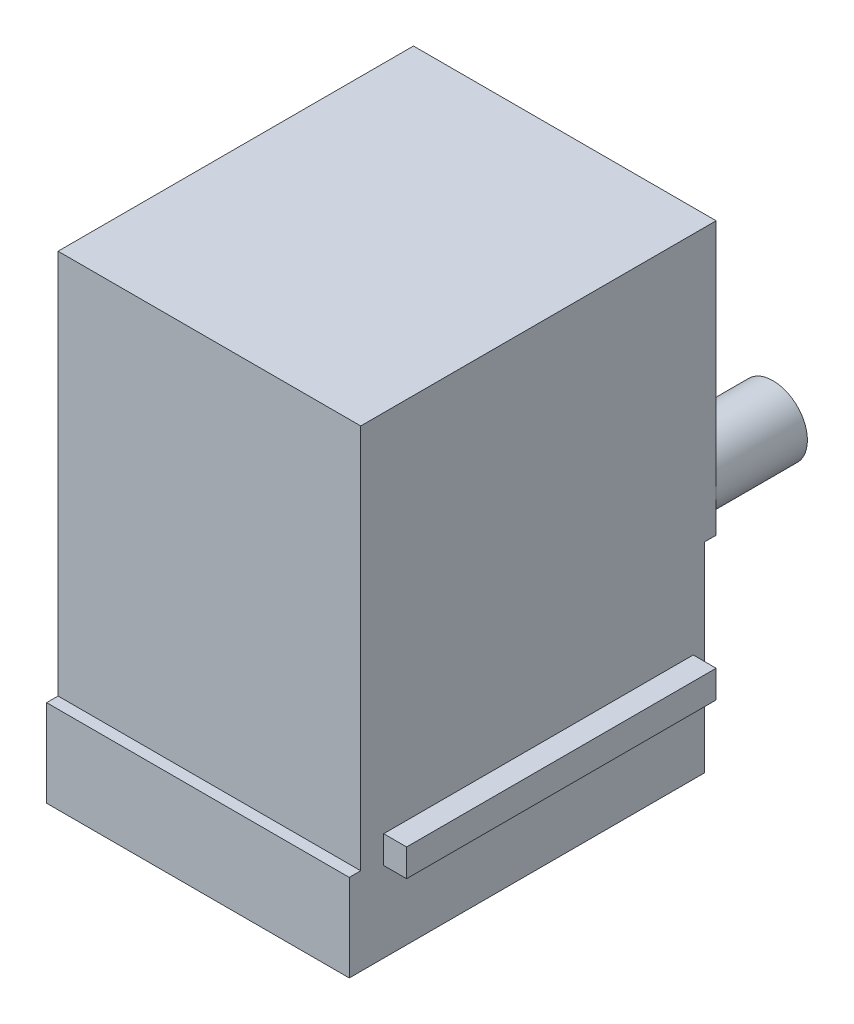
from build123d import *

# Parameters (mm, degrees)
SKETCH1_W           = 13.2
SKETCH1_H           = 20.6
BOSS_EXTRUDE1_DEPTH = 15.5
SKETCH2_R           = 1.5
BOSS_EXTRUDE2_DEPTH = 4
SKETCH3_W           = 13.2
SKETCH3_H           = 3.8
BOSS_EXTRUDE3_DEPTH = 0.5
CUT_EXTRUDE1_DEPTH  = 11
SKETCH5_W           = 4.1
SKETCH5_H           = 2.2
CUT_EXTRUDE2_DEPTH  = 5
SKETCH6_W           = 13.5
SKETCH6_H           = 1.2
BOSS_EXTRUDE5_DEPTH = 1
SKETCH7_W           = 13.5
SKETCH7_H           = 1.2
BOSS_EXTRUDE6_DEPTH = 1
SKETCH8_W           = 13.2
SKETCH8_H           = 8.722289783
CUT_EXTRUDE3_DEPTH  = 0.5


with BuildPart() as part:
    # Sketch1 → Boss-Extrude1 (new body)
    with BuildSketch(Plane.XY):
        Rectangle(SKETCH1_W, SKETCH1_H)
    extrude(amount=BOSS_EXTRUDE1_DEPTH)

    # Sketch2 → Boss-Extrude2 (add)
    with BuildSketch(Plane(origin=(0, 0, 0), x_dir=(-1, 0, 0), z_dir=(0, 0, -1))):
        with Locations((5.08, 0)):
            Circle(SKETCH2_R)
        with Locations((-5.08, 0)):
            Circle(SKETCH2_R)
    extrude(amount=BOSS_EXTRUDE2_DEPTH)

    # Sketch3 → Boss-Extrude3 (add)
    with BuildSketch(Plane.XY.offset(15.5)):
        with Locations((0, -8.4)):
            Rectangle(SKETCH3_W, SKETCH3_H)
    extrude(amount=BOSS_EXTRUDE3_DEPTH)

    # Sketch4 → Cut-Extrude1 (cut)
    with BuildSketch(Plane.XZ.offset(10.3)):
        Polygon((-3.6, 15), (3.6, 15), (3.6, 13), (4.6, 13), (4.6, 11), (5.6, 11), (5.6, 8.4), (4.6, 8.4), (4.6, 6.1), (3.6, 6.1), (3.6, 4), (-3.6, 4), (-3.6, 6.1), (-4.6, 6.1), (-4.6, 8.4), (-5.6, 8.4), (-5.6, 11), (-4.6, 11), (-4.6, 13), (-3.6, 13), align=None)
    extrude(amount=-CUT_EXTRUDE1_DEPTH, mode=Mode.SUBTRACT)

    # Sketch5 → Cut-Extrude2 (cut)
    with BuildSketch(Plane.XZ.offset(10.3)):
        with Locations((0.05, 2.9)):
            Rectangle(SKETCH5_W, SKETCH5_H)
    extrude(amount=-CUT_EXTRUDE2_DEPTH, mode=Mode.SUBTRACT)

    # Sketch6 → Boss-Extrude5 (add)
    with BuildSketch(Plane.ZY.offset(6.6)):
        with Locations((7.75, -7.4)):
            Rectangle(SKETCH6_W, SKETCH6_H)
    extrude(amount=BOSS_EXTRUDE5_DEPTH)

    # Sketch7 → Boss-Extrude6 (add)
    with BuildSketch(Plane(origin=(6.6, 0, 0), x_dir=(0, 0, -1), z_dir=(1, 0, 0))):
        with Locations((-7.75, -6.2)):
            Rectangle(SKETCH7_W, SKETCH7_H)
    extrude(amount=BOSS_EXTRUDE6_DEPTH)

    # Sketch8 → Cut-Extrude3 (cut)
    with BuildSketch(Plane(origin=(0, 0, 0), x_dir=(-1, 0, 0), z_dir=(0, 0, -1))):
        with Locations((0, -5.938855109)):
            Rectangle(SKETCH8_W, SKETCH8_H)
    extrude(amount=-CUT_EXTRUDE3_DEPTH, mode=Mode.SUBTRACT)


solid = part.part
